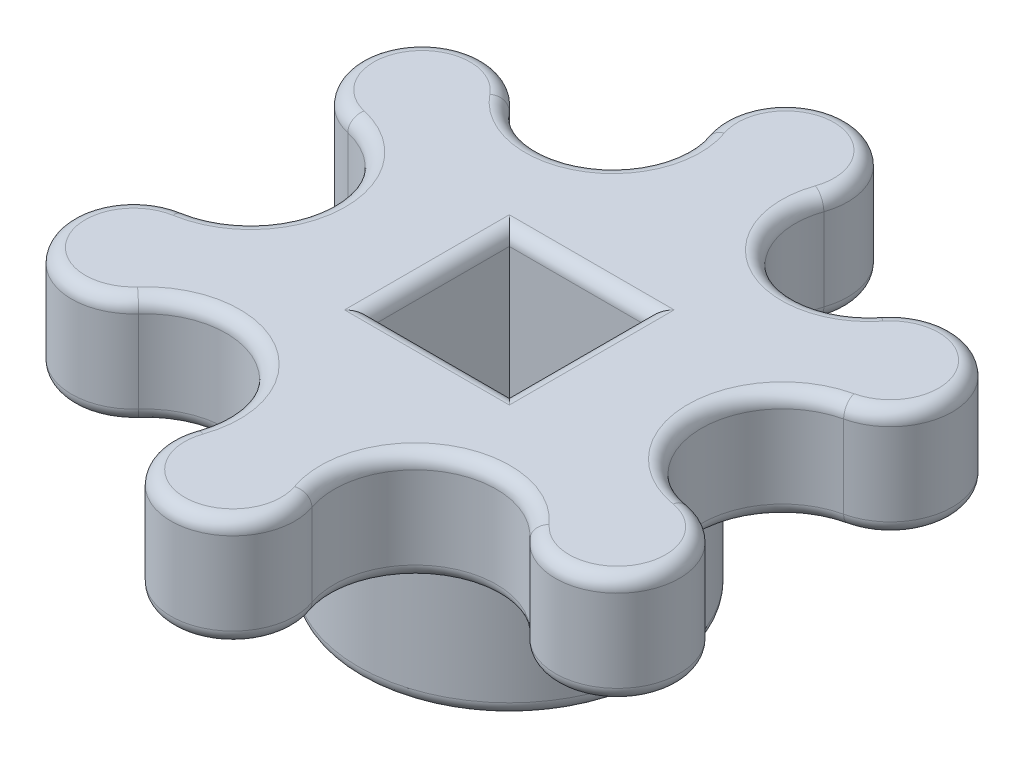
from build123d import *

# Parameters (mm, degrees)
ESQUISSE1_W        = 5
ESQUISSE1_H        = 5
BOSS_EXTRU_1_DEPTH = 4
ESQUISSE2_R        = 5.5
ESQUISSE2_W        = 5
ESQUISSE2_H        = 5
BOSS_EXTRU_2_DEPTH = 5
CONG_3_R           = 0.5
CONG_1_R           = 0.5


with BuildPart() as part:
    # Esquisse1 → Boss.-Extru.1 (new body)
    with BuildSketch(Plane(origin=(0, 0, 0), x_dir=(1, 0, 0), z_dir=(0, 1, 0))):
        with BuildLine():
            ThreePointArc((2.130984579, 9.317842466), (0, 12.320723333), (-2.130984579, 9.317842466))
            ThreePointArc((-2.130984579, 9.317842466), (-3.365390646, 6.082465583), (-6.76223985, 6.755397524))
            ThreePointArc((-6.76223985, 6.755397524), (-10.438408067, 6.54521661), (-9.026352968, 3.144556502))
            ThreePointArc((-9.026352968, 3.144556502), (-6.729057695, 0.184054327), (-9.184749378, -2.646443343))
            ThreePointArc((-9.184749378, -2.646443343), (-10.780585013, -5.964831114), (-7.121402482, -6.375649785))
            ThreePointArc((-7.121402482, -6.375649785), (-3.418785155, -5.798793109), (-2.130984579, -9.317842466))
            ThreePointArc((-2.130984579, -9.317842466), (0, -12.320723333), (2.130984579, -9.317842466))
            ThreePointArc((2.130984579, -9.317842466), (3.418785155, -5.798793109), (7.121402482, -6.375649785))
            ThreePointArc((7.121402482, -6.375649785), (10.780585013, -5.964831114), (9.184749378, -2.646443343))
            ThreePointArc((9.184749378, -2.646443343), (6.729057695, 0.184054327), (9.026352968, 3.144556502))
            ThreePointArc((9.026352968, 3.144556502), (10.438408067, 6.54521661), (6.76223985, 6.755397524))
            ThreePointArc((6.76223985, 6.755397524), (3.365390646, 6.082465583), (2.130984579, 9.317842466))
        make_face()
        Rectangle(ESQUISSE1_W, ESQUISSE1_H, mode=Mode.SUBTRACT)
    extrude(amount=BOSS_EXTRU_1_DEPTH)

    # Esquisse2 → Boss.-Extru.2 (add)
    with BuildSketch(Plane.XZ):
        Circle(ESQUISSE2_R)
        Rectangle(ESQUISSE2_W, ESQUISSE2_H, mode=Mode.SUBTRACT)
    extrude(amount=BOSS_EXTRU_2_DEPTH)

    # Congé3
    cong_3_edges = [part.edges().sort_by_distance(p)[0] for p in [
        (10.438408067, 0, -6.54521661),
        (6.729057695, 0, -0.184054327),
        (10.780585013, 0, 5.964831114),
        (3.418785155, 0, 5.798793109),
        (0, 0, 12.320723333),
        (-3.418785155, 0, 5.798793109),
        (-10.780585013, 0, 5.964831114),
        (-6.729057695, 0, -0.184054327),
        (-10.438408067, 0, -6.54521661),
        (-3.365390646, 0, -6.082465583),
        (0, 0, -12.320723333),
        (3.365390646, 0, -6.082465583),
        (2.5, 4, 0),
        (0, 4, -2.5),
        (-2.5, 4, 0),
        (0, 4, 2.5),
        (-5.5, 0, 0),
        (2.5, -5, 0),
        (0, -5, 2.5),
        (-2.5, -5, 0),
        (0, -5, -2.5),
    ]]
    fillet(cong_3_edges, radius=CONG_3_R)

    # Congé1
    cong_1_edges = [part.edges().sort_by_distance(p)[0] for p in [
        (-3.365390646, 4, -6.082465583),
        (-10.438408067, 4, -6.54521661),
        (-6.729057695, 4, -0.184054327),
        (-10.780585013, 4, 5.964831114),
        (-3.418785155, 4, 5.798793109),
        (0, 4, 12.320723333),
        (3.418785155, 4, 5.798793109),
        (10.780585013, 4, 5.964831114),
        (6.729057695, 4, -0.184054327),
        (10.438408067, 4, -6.54521661),
        (3.365390646, 4, -6.082465583),
        (-5.5, -5, 0),
        (0, 4, -12.320723333),
    ]]
    fillet(cong_1_edges, radius=CONG_1_R)


solid = part.part
